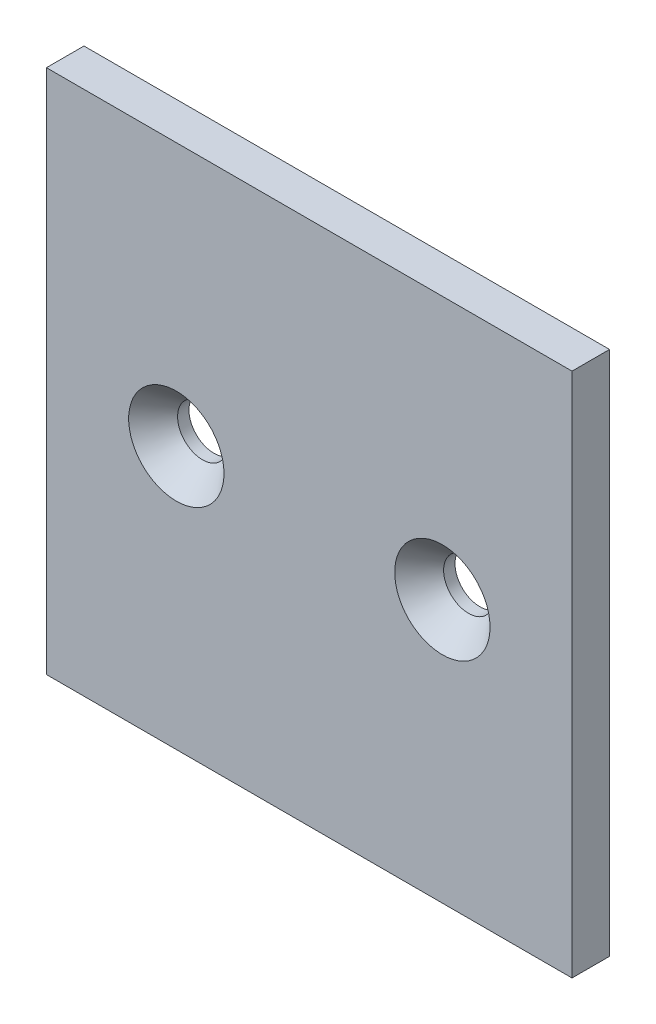
from build123d import *

# Parameters (mm, degrees)
SKETCH1_W                                         = 88.9
SKETCH1_H                                         = 88.9
SKETCH1_R                                         = 4.191
SKETCH1_R_2                                       = 4.15
BOSS_EXTRUDE1_DEPTH                               = 6.35
CSK_FOR_5_16_FLAT_HEAD_MACHINE_SCREW1_D           = 8.4328
CSK_FOR_5_16_FLAT_HEAD_MACHINE_SCREW1_DEPTH       = 32.766
CSK_FOR_5_16_FLAT_HEAD_MACHINE_SCREW1_CSINK_D     = 16.129
CSK_FOR_5_16_FLAT_HEAD_MACHINE_SCREW1_CSINK_ANGLE = 82
CSK_FOR_5_16_FLAT_HEAD_MACHINE_SCREW1_TIP         = 2.533468714


with BuildPart() as part:
    # Sketch1 → Boss-Extrude1 (new body)
    with BuildSketch(Plane.XY):
        Rectangle(SKETCH1_W, SKETCH1_H)
        with Locations((-22.479, 0)):
            Circle(SKETCH1_R, mode=Mode.SUBTRACT)
        with Locations((22.521, 0)):
            Circle(SKETCH1_R_2, mode=Mode.SUBTRACT)
    extrude(amount=-BOSS_EXTRUDE1_DEPTH)

    # CSK for 5/16 Flat Head Machine Screw1
    with Locations(Plane(origin=(-22.479, 0, 0), x_dir=(1, 0, 0), z_dir=(0, 0, 1))):
        with Locations((0, 0), (45, 0)):
            CounterSinkHole(CSK_FOR_5_16_FLAT_HEAD_MACHINE_SCREW1_D / 2, CSK_FOR_5_16_FLAT_HEAD_MACHINE_SCREW1_CSINK_D / 2, depth=CSK_FOR_5_16_FLAT_HEAD_MACHINE_SCREW1_DEPTH, counter_sink_angle=CSK_FOR_5_16_FLAT_HEAD_MACHINE_SCREW1_CSINK_ANGLE)
            with Locations((0, 0, -(CSK_FOR_5_16_FLAT_HEAD_MACHINE_SCREW1_DEPTH + CSK_FOR_5_16_FLAT_HEAD_MACHINE_SCREW1_TIP / 2))):  # 118° drill point
                Cone(0, CSK_FOR_5_16_FLAT_HEAD_MACHINE_SCREW1_D / 2, CSK_FOR_5_16_FLAT_HEAD_MACHINE_SCREW1_TIP, mode=Mode.SUBTRACT)


solid = part.part
